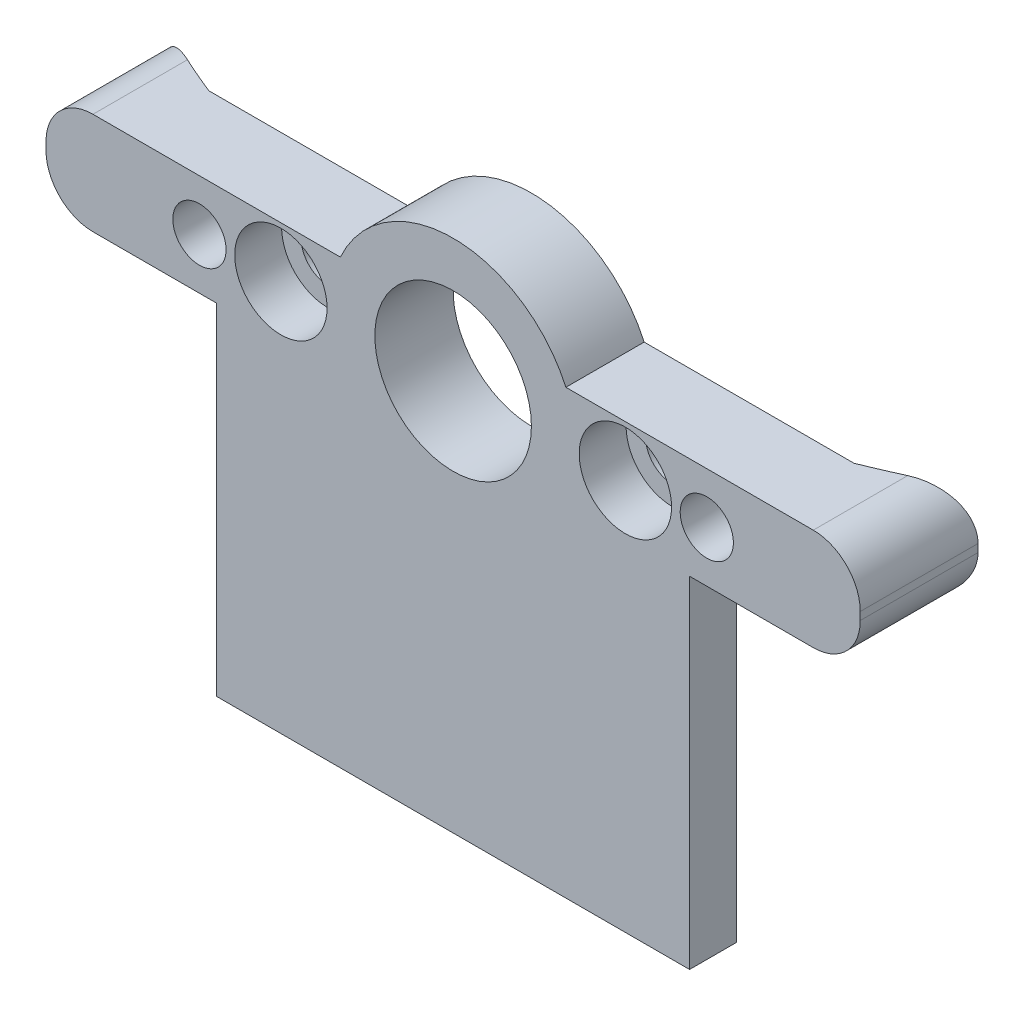
from build123d import *

# Parameters (mm, degrees)
CROQUIS1_R              = 5
SALIENTE_EXTRUIR1_DEPTH = 5
CROQUIS2_R              = 1.7
CORTAR_EXTRUIR1_DEPTH   = 5
CROQUIS3_R              = 2.95
CORTAR_EXTRUIR2_DEPTH   = 3
SALIENTE_EXTRUIR2_DEPTH = 3.25
CROQUIS5_R              = 1.7
CORTAR_EXTRUIR3_DEPTH   = 10
CORTAR_EXTRUIR4_DEPTH   = 1.7
REDONDEO1_R             = 3
SALIENTE_EXTRUIR3_DEPTH = 2.5
SALIENTE_EXTRUIR4_DEPTH = 21.75


with BuildPart() as part:
    # Croquis1 → Saliente-Extruir1 (new body)
    with BuildSketch(Plane.XY):
        with BuildLine():
            Line((-7.200520814, 3.25), (-26, 3.25))
            Line((-26, 3.25), (-26, -3.25))
            Line((-26, -3.25), (-7.200520814, -3.25))
            ThreePointArc((-7.200520814, -3.25), (0, -7.9), (7.200520814, -3.25))
            Line((7.200520814, -3.25), (26, -3.25))
            Line((26, -3.25), (26, 3.25))
            Line((26, 3.25), (7.200520814, 3.25))
            ThreePointArc((7.200520814, 3.25), (0, 7.9), (-7.200520814, 3.25))
        make_face()
        Circle(CROQUIS1_R, mode=Mode.SUBTRACT)
    extrude(amount=SALIENTE_EXTRUIR1_DEPTH)

    # Croquis2 → Cortar-Extruir1 (cut)
    with BuildSketch(Plane.XY.offset(5)):
        with Locations((-11, 0)):
            Circle(CROQUIS2_R)
        with Locations((11, 0)):
            Circle(CROQUIS2_R)
    extrude(amount=-CORTAR_EXTRUIR1_DEPTH, mode=Mode.SUBTRACT)

    # Croquis3 → Cortar-Extruir2 (cut)
    with BuildSketch(Plane.XY.offset(5)):
        with Locations((-11, 0)):
            Circle(CROQUIS3_R)
        with Locations((11, 0)):
            Circle(CROQUIS3_R)
    extrude(amount=-CORTAR_EXTRUIR2_DEPTH, mode=Mode.SUBTRACT)

    # Croquis4 → Saliente-Extruir2 (add, symmetric)
    with BuildSketch(Plane(origin=(0, 0, 0), x_dir=(1, 0, 0), z_dir=(0, 1, 0))):
        with BuildLine():
            Line((-26, 0), (-20.6, 0))
            ThreePointArc((-20.6, 0), (-23.334154241, 1.186812342), (-26, 2.52))
            Line((-26, 2.52), (-26, 0))
        make_face()
    saliente_extruir2 = extrude(amount=SALIENTE_EXTRUIR2_DEPTH, both=True)

    # Croquis5 → Cortar-Extruir3 (cut)
    with BuildSketch(Plane.XY.offset(5)):
        with Locations((-16.2, 0)):
            Circle(CROQUIS5_R)
    cortar_extruir3 = extrude(amount=-CORTAR_EXTRUIR3_DEPTH, mode=Mode.SUBTRACT)

    # Croquis6 → Cortar-Extruir4 (cut)
    with BuildSketch(Plane(origin=(0, 0, 0), x_dir=(-1, 0, 0), z_dir=(0, 0, -1))):
        Polygon((19.55, 0), (17.875, 2.901185103), (14.525, 2.901185103), (12.85, 0), (14.525, -2.901185103), (17.875, -2.901185103), align=None)
    cortar_extruir4 = extrude(amount=-CORTAR_EXTRUIR4_DEPTH, mode=Mode.SUBTRACT)

    # Simetría2: Saliente-Extruir2, Cortar-Extruir3, Cortar-Extruir4 across plane
    add(saliente_extruir2.mirror(Plane(origin=(0, 0, 0), x_dir=(0, 0, 1), z_dir=(1, 0, 0))))
    add(cortar_extruir3.mirror(Plane(origin=(0, 0, 0), x_dir=(0, 0, 1), z_dir=(1, 0, 0))), mode=Mode.SUBTRACT)
    add(cortar_extruir4.mirror(Plane(origin=(0, 0, 0), x_dir=(0, 0, 1), z_dir=(1, 0, 0))), mode=Mode.SUBTRACT)

    # Redondeo1
    redondeo1_edges = [part.edges().sort_by_distance(p)[0] for p in [
        (-26, 3.25, 1.24),
        (26, 3.25, 1.24),
        (26, -3.25, 1.24),
        (-26, -3.25, 1.24),
    ]]
    fillet(redondeo1_edges, radius=REDONDEO1_R)

    # Croquis7 → Saliente-Extruir3 (add)
    with BuildSketch(Plane.XY.offset(5)):
        with BuildLine():
            Line((-15.100260407, -3.25), (-7.200520814, -3.25))
            ThreePointArc((-7.200520814, -3.25), (0, -7.9), (7.200520814, -3.25))
            Line((7.200520814, -3.25), (15.100260407, -3.25))
            Line((15.100260407, -3.25), (15.100260407, -25))
            Line((15.100260407, -25), (-15.100260407, -25))
            Line((-15.100260407, -25), (-15.100260407, -3.25))
        make_face()
    extrude(amount=-SALIENTE_EXTRUIR3_DEPTH)

    # Croquis8 → Saliente-Extruir4 (add)
    with BuildSketch(Plane.XZ.offset(25)):
        with BuildLine():
            Line((-15.100260407, 2.5), (-15.100260407, 2))
            ThreePointArc((-15.100260407, 2), (-13.952935396, 2.262304947), (-12.800260407, 2.5))
            Line((-12.800260407, 2.5), (-15.100260407, 2.5))
        make_face()
        with BuildLine():
            Line((15.100260407, 2.5), (12.800260407, 2.5))
            ThreePointArc((12.800260407, 2.5), (13.952935396, 2.262304947), (15.100260407, 2))
            Line((15.100260407, 2), (15.100260407, 2.5))
        make_face()
    extrude(amount=-SALIENTE_EXTRUIR4_DEPTH)


solid = part.part
